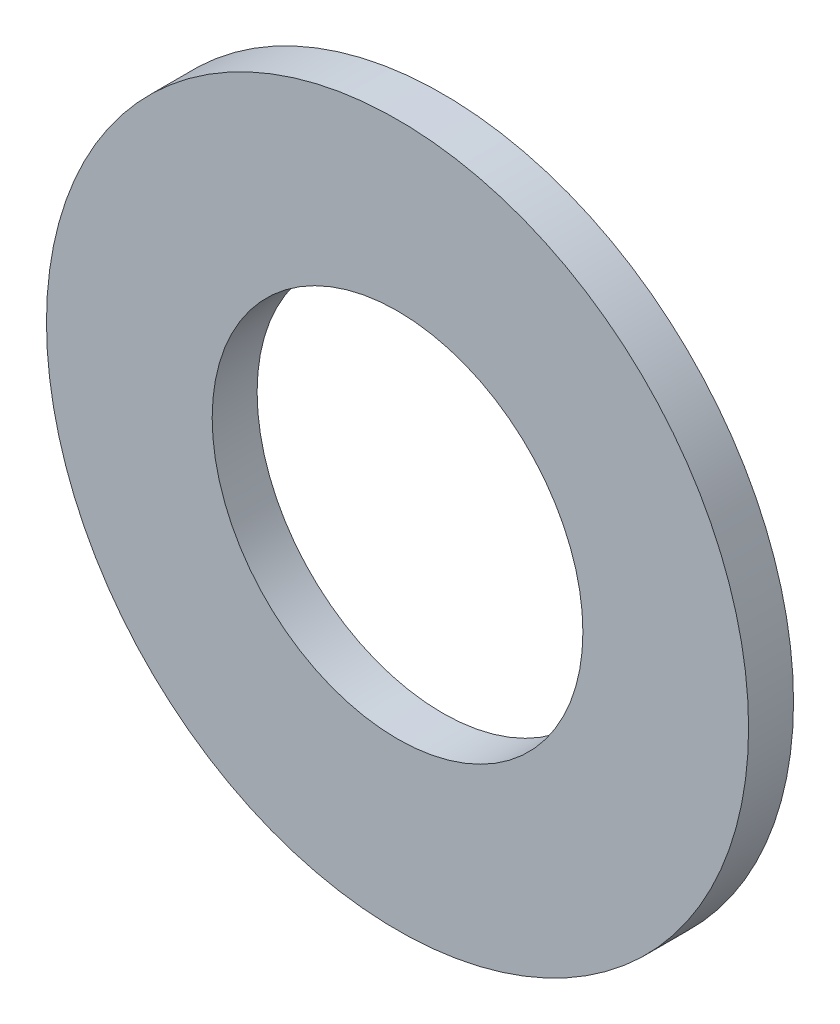
from build123d import *

# Parameters (mm, degrees)
SKETCH1_R           = 6.35
SKETCH1_R_2         = 3.3528
BOSS_EXTRUDE1_DEPTH = 0.8128


with BuildPart() as part:
    # Sketch1 → Boss-Extrude1 (new body)
    with BuildSketch(Plane.XY):
        Circle(SKETCH1_R)
        Circle(SKETCH1_R_2, mode=Mode.SUBTRACT)
    extrude(amount=BOSS_EXTRUDE1_DEPTH)


solid = part.part
